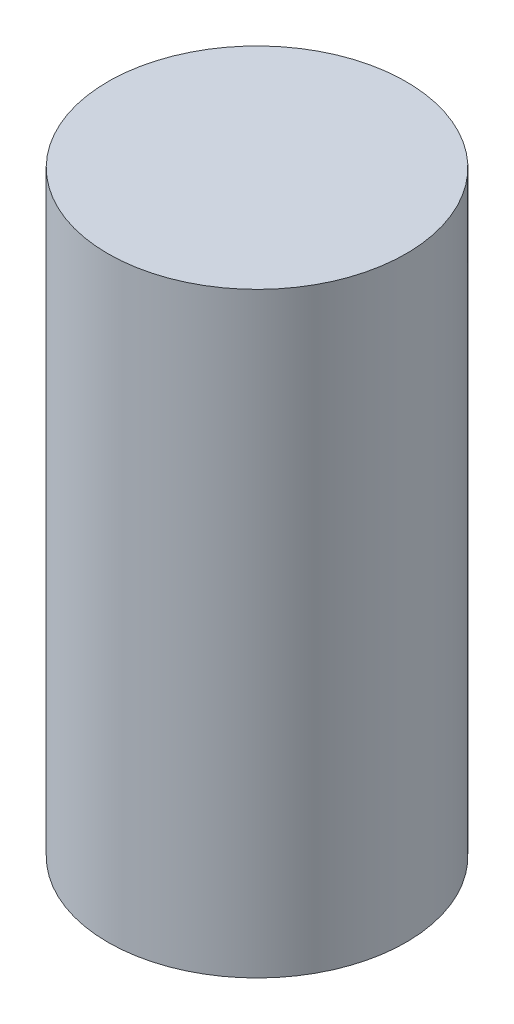
from build123d import *

# Parameters (mm, degrees)
SKETCH1_R           = 10
BOSS_EXTRUDE1_DEPTH = 40


with BuildPart() as part:
    # Sketch1 → Boss-Extrude1 (new body)
    with BuildSketch(Plane(origin=(0, 0, 0), x_dir=(1, 0, 0), z_dir=(0, 1, 0))):
        Circle(SKETCH1_R)
    extrude(amount=BOSS_EXTRUDE1_DEPTH)


solid = part.part
